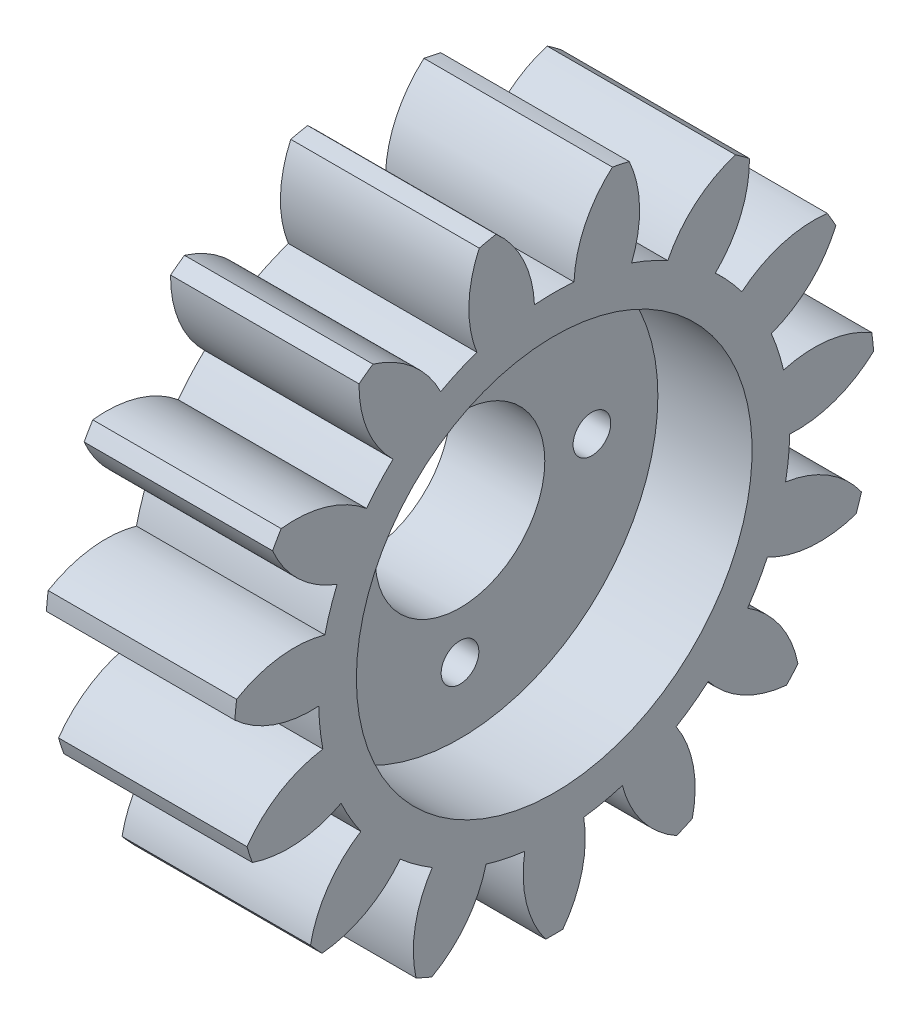
from build123d import *

# Parameters (mm, degrees)
BASPROSKE_W         = 10
BASPROSKE_H         = 17
TOOTHCUT_DEPTH      = 27.038433133
TEETHCUTS_COUNT     = 15
BORSKE_R            = 10.5
BORE_DEPTH          = 10
SKETCH1_R           = 10.5
SKETCH1_R_2         = 1
SKETCH1_R_3         = 4.5
BOSS_EXTRUDE1_DEPTH = 5


with BuildPart() as part:
    # BasProSke → Base-Revolve (revolve)
    with BuildSketch(Plane(origin=(0, 0, 0), x_dir=(1, 0, 0), z_dir=(0, 1, 0)), mode=Mode.PRIVATE) as base_revolve_sk:
        with Locations((5, 8.5)):
            Rectangle(BASPROSKE_W, BASPROSKE_H)
    revolve(base_revolve_sk.sketch.rotate(Axis((-10, 0, 0), (1, 0, 0)), 180), axis=Axis((-10, 0, 0), (1, 0, 0)))

    # TooCutSke → ToothCut (cut, through all)
    with BuildSketch(Plane(origin=(0, 0, 0), x_dir=(0, 0, -1), z_dir=(1, 0, 0))):
        with BuildLine():
            ThreePointArc((1.050056448, 12.454813626), (0, 12.499), (-1.050056448, 12.454813626))
            ThreePointArc((-1.050056448, 12.454813626), (-1.638118106, 14.809604533), (-3.110934279, 16.73876737))
            ThreePointArc((-3.110934279, 16.73876737), (0, 17.0254), (3.110934279, 16.73876737))
            ThreePointArc((3.110934279, 16.73876737), (1.638118106, 14.809604533), (1.050056448, 12.454813626))
        make_face()
    toothcut = extrude(amount=TOOTHCUT_DEPTH, mode=Mode.SUBTRACT)

    # TeethCuts: ToothCut ×15 about axis
    teethcuts_axis = Axis((0, 0, 0), (1, 0, 0))
    for i in range(1, TEETHCUTS_COUNT):
        add(toothcut.rotate(teethcuts_axis, i * 360 / TEETHCUTS_COUNT), mode=Mode.SUBTRACT)

    # BorSke → Bore (cut, symmetric)
    with BuildSketch(Plane(origin=(0, 0, 0), x_dir=(0, 0, -1), z_dir=(1, 0, 0))):
        with Locations(Location((0, 0, 0), (0, 0, 180))):
            Circle(BORSKE_R)
    extrude(amount=BORE_DEPTH, both=True, mode=Mode.SUBTRACT)

    # Sketch1 → Boss-Extrude1 (add)
    with BuildSketch(Plane(origin=(0, 0, 0), x_dir=(0, 0, -1), z_dir=(1, 0, 0))):
        with Locations(Location((0, 0, 0), (0, 0, 180))):
            Circle(SKETCH1_R)
        with Locations((7, 0)):
            Circle(SKETCH1_R_2, mode=Mode.SUBTRACT)
        with Locations((-7, 0)):
            Circle(SKETCH1_R_2, mode=Mode.SUBTRACT)
        with Locations((0, 7)):
            Circle(SKETCH1_R_2, mode=Mode.SUBTRACT)
        with Locations((0, -7)):
            Circle(SKETCH1_R_2, mode=Mode.SUBTRACT)
        Circle(SKETCH1_R_3, mode=Mode.SUBTRACT)
    extrude(amount=BOSS_EXTRUDE1_DEPTH)


solid = part.part
